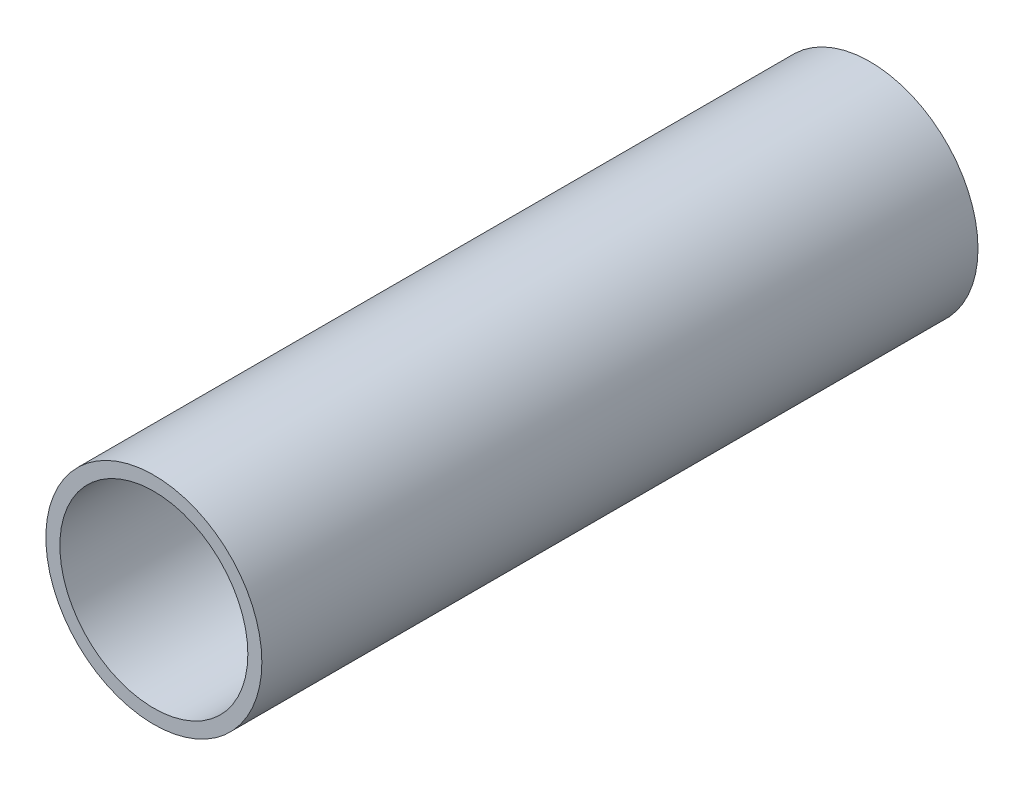
from build123d import *

# Parameters (mm, degrees)
SKETCH1_R           = 30.1625
SKETCH1_R_2         = 26.2509
EXTRUDE_THIN1_DEPTH = 100


with BuildPart() as part:
    # Sketch1 → Extrude-Thin1 (new body, symmetric)
    with BuildSketch(Plane.XY):
        Circle(SKETCH1_R)
        Circle(SKETCH1_R_2, mode=Mode.SUBTRACT)
    extrude(amount=EXTRUDE_THIN1_DEPTH, both=True)


solid = part.part
